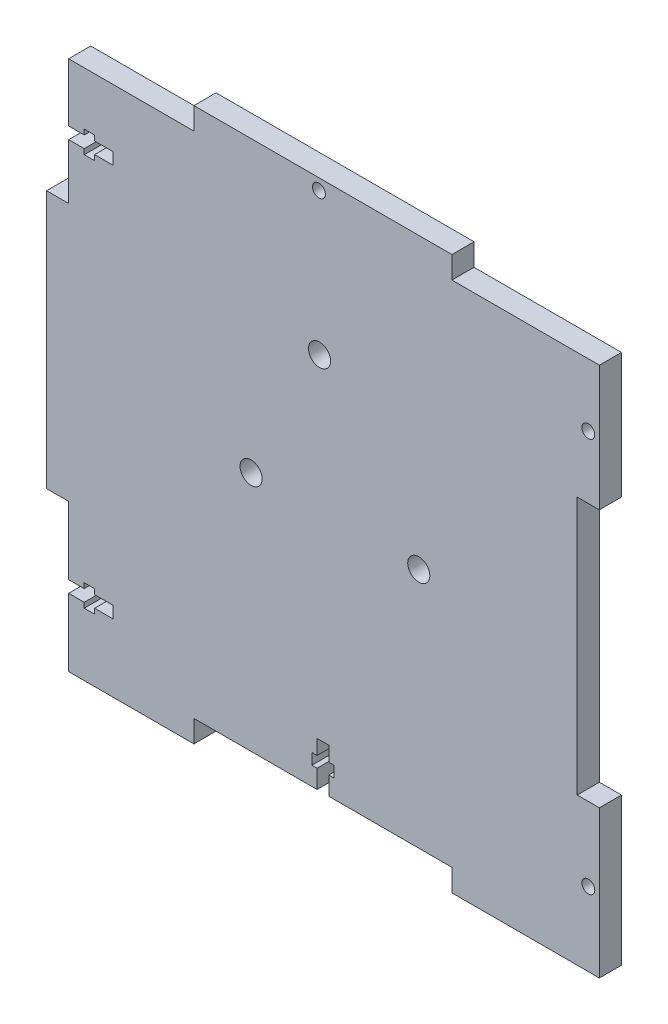
from build123d import *

# Parameters (mm, degrees)
SKETCH1_R           = 1.75
BOSS_EXTRUDE2_DEPTH = 6
SKETCH3_R           = 3
CUT_EXTRUDE1_DEPTH  = 7
SKETCH4_R           = 3
CUT_EXTRUDE2_DEPTH  = 7


with BuildPart() as part:
    # Sketch1 → Boss-Extrude2 (new body)
    with BuildSketch(Plane.XY):
        Polygon((72, 72), (32, 72), (32, 78), (-38, 78), (-38, 72), (-72, 72), (-72, 56.2), (-67.772810154, 56.2), (-67.772810154, 57.6), (-64.957983727, 57.6), (-64.957983727, 56.2), (-60, 56.2), (-60, 53), (-64.957983727, 53), (-64.957983727, 51.568504207), (-67.772810154, 51.568504207), (-67.772810154, 53), (-72, 53), (-72, 38), (-78, 38), (-78, -32), (-72, -32), (-72, -50.4), (-67.78187279, -50.4), (-67.78187279, -49), (-64.967046362, -49), (-64.967046362, -50.4), (-60, -50.4), (-60, -53.6), (-64.967046362, -53.6), (-64.967046362, -55), (-67.78187279, -55), (-67.78187279, -53.6), (-72, -53.6), (-72, -72), (-38, -72), (-38, -66), (-4.6, -66), (-4.6, -61), (-6, -61), (-6, -58), (-4.6, -58), (-4.6, -54), (-1.4, -54), (-1.4, -58), (0, -58), (0, -61), (-1.4, -61), (-1.4, -66), (32, -66), (32, -72), (72, -72), (72, -32), (66, -32), (66, 38), (72, 38), align=None)
        with Locations((69, -52)):
            Circle(SKETCH1_R, mode=Mode.SUBTRACT)
        with Locations((69, 55)):
            Circle(SKETCH1_R, mode=Mode.SUBTRACT)
        with Locations((-4.09, 75)):
            Circle(SKETCH1_R, mode=Mode.SUBTRACT)
    extrude(amount=BOSS_EXTRUDE2_DEPTH)

    # Sketch3 → Cut-Extrude1 (cut, through all)
    with BuildSketch(Plane(origin=(0, 0, 0), x_dir=(-1, 0, 0), z_dir=(0, 0, -1))):
        with Locations((3.924742841, 36.491728523)):
            Circle(SKETCH3_R)
    extrude(amount=-CUT_EXTRUDE1_DEPTH, mode=Mode.SUBTRACT)

    # Sketch4 → Cut-Extrude2 (cut, through all)
    with BuildSketch(Plane(origin=(0, 0, 0), x_dir=(-1, 0, 0), z_dir=(0, 0, -1))):
        with Locations((-23, -0.5)):
            Circle(SKETCH4_R)
        with Locations((22.5, -0.5)):
            Circle(SKETCH4_R)
    extrude(amount=-CUT_EXTRUDE2_DEPTH, mode=Mode.SUBTRACT)


solid = part.part
